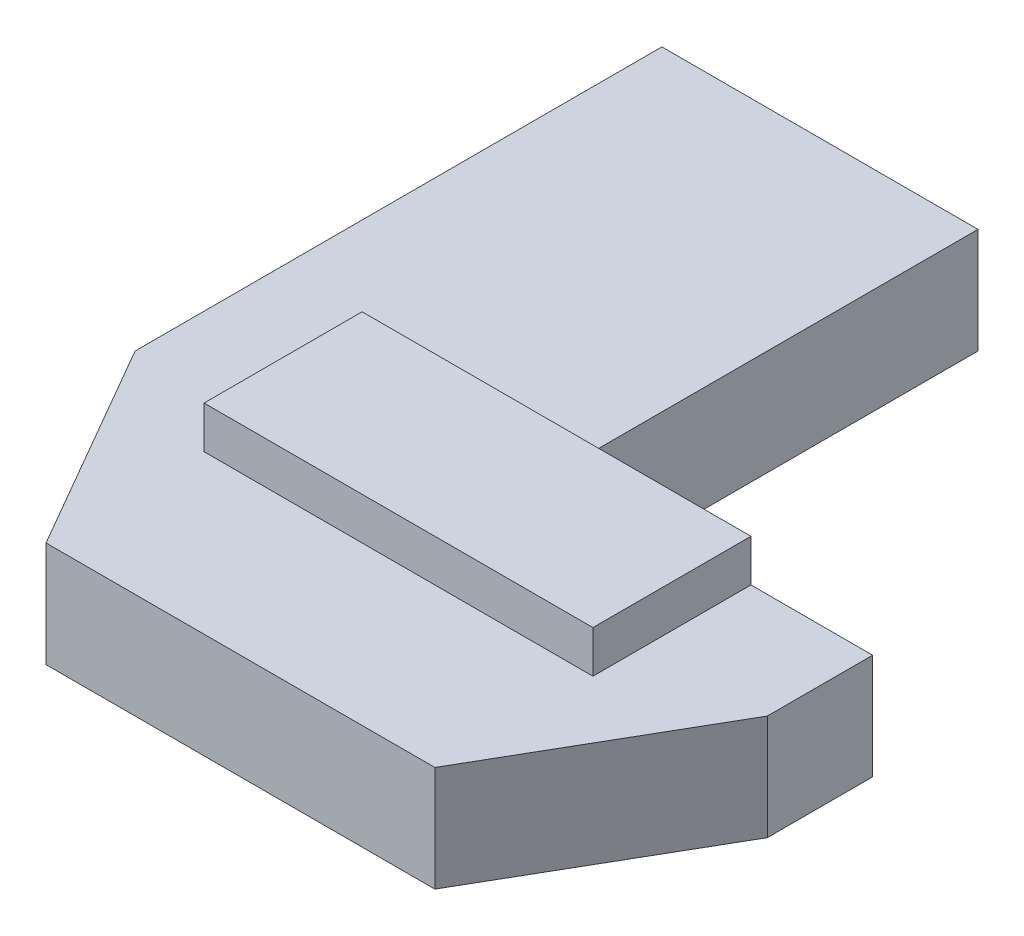
from build123d import *

# Parameters (mm, degrees)
BOSS_EXTRUDE1_DEPTH = 5
CUT_EXTRUDE1_REACH  = 7
SKETCH3_W           = 18.452994616
SKETCH3_H           = 7.5
BOSS_EXTRUDE2_DEPTH = 2


with BuildPart() as part:
    # Sketch1 → Boss-Extrude1 (new body)
    with BuildSketch(Plane(origin=(0, 0, 0), x_dir=(1, 0, 0), z_dir=(0, 1, 0))):
        Polygon((0, 0), (0, 20), (-25, 20), (-25, -20), (-8.000491869, -49.444011787), (8.000491869, -49.444011787), (25, -20), (25, 0), align=None)
    extrude(amount=BOSS_EXTRUDE1_DEPTH)

    # Sketch2 → Cut-Extrude1 (cut, up to next)
    with BuildSketch(Plane(origin=(0, 5, 0), x_dir=(1, 0, 0), z_dir=(0, 1, 0)), mode=Mode.PRIVATE) as cut_extrude1_sk1:
        Polygon((-15, 20), (-15, -5), (-9.226497308, -15), (9.226497308, -15), (15, -5), (15, 0), (25, 0), (25, -20), (8.000491869, -49.444011787), (-8.000491869, -49.444011787), (-25, -20), (-25, 20), align=None)
    cut_extrude1_tool1 = extrude(cut_extrude1_sk1.sketch, amount=-CUT_EXTRUDE1_REACH, mode=Mode.PRIVATE) & part.part
    add(cut_extrude1_tool1.solids().sort_by_distance((-2.247946, 5, 20.557757))[0], mode=Mode.SUBTRACT)

    # Sketch3 → Boss-Extrude2 (add)
    with BuildSketch(Plane(origin=(0, 5, 0), x_dir=(1, 0, 0), z_dir=(0, 1, 0))):
        with Locations((0, -3.75)):
            Rectangle(SKETCH3_W, SKETCH3_H)
    extrude(amount=BOSS_EXTRUDE2_DEPTH)


solid = part.part
